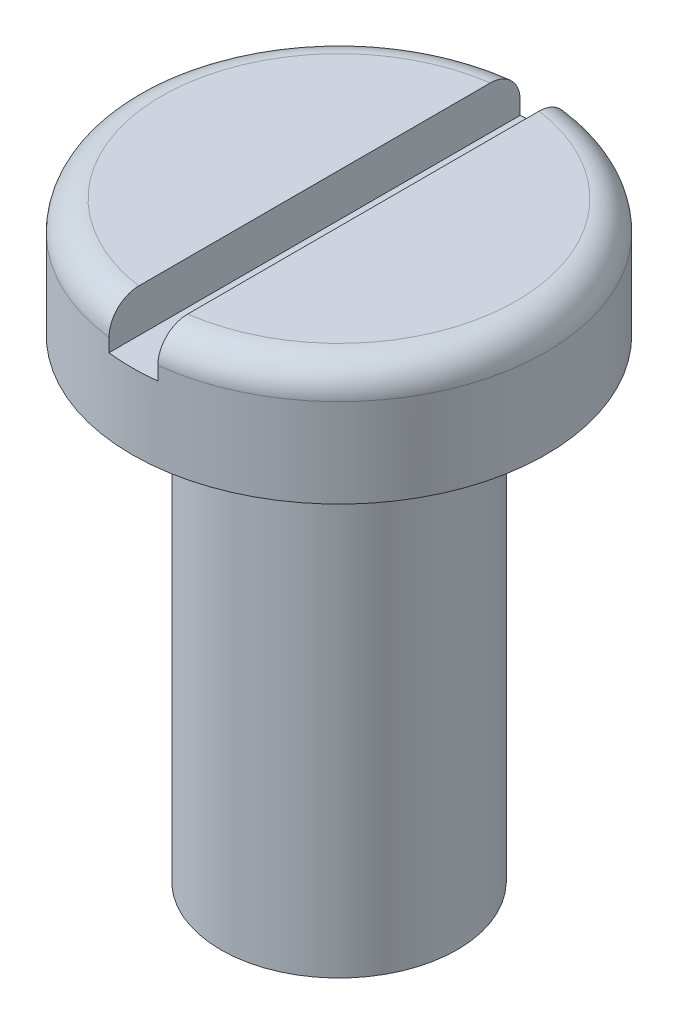
from build123d import *

# Parameters (mm, degrees)
SKETCH1_R               = 3.5
SKETCH1_R_2             = 2
BOSS_EXTRUDE1_DEPTH     = 2
SKETCH1_2_R             = 2
BOSS_EXTRUDE2_DEPTH     = 10
SKETCH2_W               = 0.824993444
SKETCH2_H               = 1.453522708
CUT_EXTRUDE1_DEPTH      = 4.5
CUT_EXTRUDE1_DEPTH_BACK = 4.5
FILLET2_R               = 0.5


with BuildPart() as part:
    # Sketch1 → Boss-Extrude1 (new body)
    with BuildSketch(Plane(origin=(0, 0, 0), x_dir=(1, 0, 0), z_dir=(0, 1, 0))):
        Circle(SKETCH1_R)
        Circle(SKETCH1_R_2, mode=Mode.SUBTRACT)
    extrude(amount=-BOSS_EXTRUDE1_DEPTH)

    # Sketch1_2 → Boss-Extrude2 (add)
    with BuildSketch(Plane(origin=(0, 0, 0), x_dir=(1, 0, 0), z_dir=(0, 1, 0))):
        Circle(SKETCH1_2_R)
    extrude(amount=-BOSS_EXTRUDE2_DEPTH)

    # Sketch2 → Cut-Extrude1 (cut, two sides)
    with BuildSketch(Plane.XY) as cut_extrude1_sk:
        Rectangle(SKETCH2_W, SKETCH2_H)
    extrude(amount=CUT_EXTRUDE1_DEPTH, mode=Mode.SUBTRACT)
    extrude(cut_extrude1_sk.sketch, amount=-CUT_EXTRUDE1_DEPTH_BACK, mode=Mode.SUBTRACT)

    # Fillet2
    fillet2_edges = [part.edges().sort_by_distance(p)[0] for p in [
        (2.616652301, 0, -2.324463537),
        (-3.5, 0, 0),
    ]]
    fillet(fillet2_edges, radius=FILLET2_R)


solid = part.part
